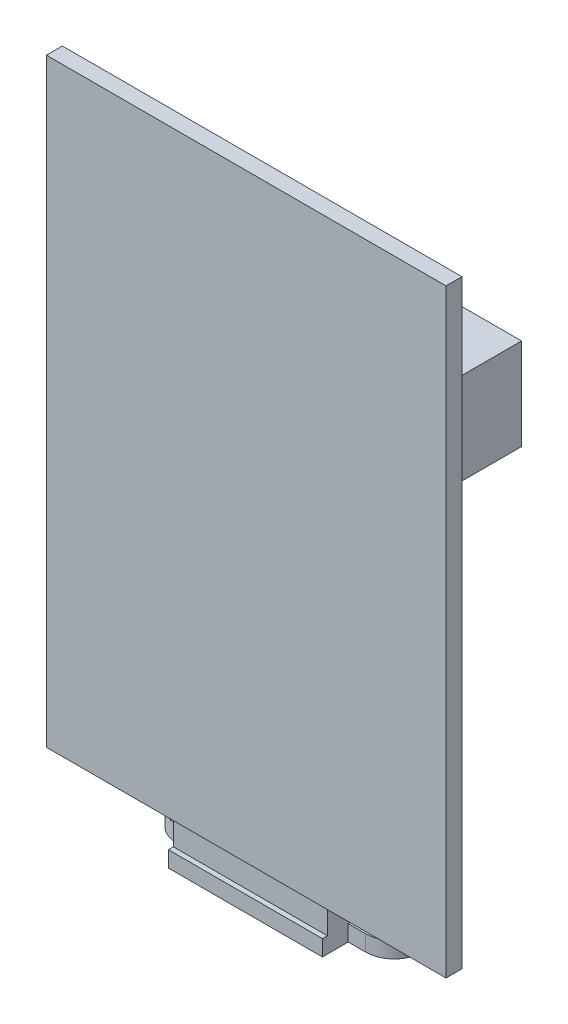
from build123d import *

# Parameters (mm, degrees)
SKETCH1_W           = 15.5
SKETCH1_H           = 11
BOSS_EXTRUDE1_DEPTH = 1.6
BOSS_EXTRUDE2_DEPTH = 1.6
SKETCH3_W           = 15.5
SKETCH3_H           = 2.7
BOSS_EXTRUDE3_DEPTH = 2.7
SKETCH4_W           = 40.2
SKETCH4_H           = 1.6
BOSS_EXTRUDE4_DEPTH = 60.3
SKETCH5_W           = 30.1
SKETCH5_H           = 9.2
BOSS_EXTRUDE5_DEPTH = 12.1
SKETCH6_R           = 2
CUT_EXTRUDE1_DEPTH  = 2
LPATTERN1_COUNT     = 6
LPATTERN1_PITCH     = 5


with BuildPart() as part:
    # Sketch1 → Boss-Extrude1 (new body)
    with BuildSketch(Plane(origin=(0, 0, 0), x_dir=(1, 0, 0), z_dir=(0, 1, 0))):
        with Locations((7.75, -5.5)):
            Rectangle(SKETCH1_W, SKETCH1_H)
    extrude(amount=BOSS_EXTRUDE1_DEPTH)

    # Sketch2 → Boss-Extrude2 (add, through all)
    with BuildSketch(Plane(origin=(0, 1.6, 0), x_dir=(1, 0, 0), z_dir=(0, 1, 0))):
        with BuildLine():
            Line((-1.75, -4), (-1.75, -2.6))
            ThreePointArc((-1.75, -2.6), (-4.65, -5.5), (-1.75, -8.4))
            Line((-1.75, -8.4), (-1.75, -7))
            ThreePointArc((-1.75, -7), (-3.25, -5.5), (-1.75, -4))
        make_face()
        with BuildLine():
            ThreePointArc((0, -3.187533784), (-0.827002716, -2.750804479), (-1.75, -2.6))
            Line((-1.75, -2.6), (-1.75, -4))
            ThreePointArc((-1.75, -4), (-0.689339828, -4.439339828), (-0.25, -5.5))
            ThreePointArc((-0.25, -5.5), (-0.689339828, -6.560660172), (-1.75, -7))
            Line((-1.75, -7), (-1.75, -8.4))
            ThreePointArc((-1.75, -8.4), (-0.827002716, -8.249195521), (0, -7.812466216))
            Line((0, -7.812466216), (0, -3.187533784))
        make_face()
        with BuildLine():
            Line((0, -2.6), (-1.75, -2.6))
            ThreePointArc((-1.75, -2.6), (-0.827002716, -2.750804479), (0, -3.187533784))
            Line((0, -3.187533784), (0, -2.6))
        make_face()
        with BuildLine():
            ThreePointArc((0, -7.812466216), (-0.827002716, -8.249195521), (-1.75, -8.4))
            Line((-1.75, -8.4), (0, -8.4))
            Line((0, -8.4), (0, -7.812466216))
        make_face()
        with BuildLine():
            ThreePointArc((20.15, -5.5), (19.300609665, -3.449390335), (17.25, -2.6))
            Line((17.25, -2.6), (17.25, -4))
            ThreePointArc((17.25, -4), (18.310660172, -4.439339828), (18.75, -5.5))
            ThreePointArc((18.75, -5.5), (18.310660172, -6.560660172), (17.25, -7))
            Line((17.25, -7), (17.25, -8.4))
            ThreePointArc((17.25, -8.4), (19.300609665, -7.550609665), (20.15, -5.5))
        make_face()
        with BuildLine():
            Line((17.25, -4), (17.25, -2.6))
            ThreePointArc((17.25, -2.6), (16.327002716, -2.750804479), (15.5, -3.187533784))
            Line((15.5, -3.187533784), (15.5, -7.812466216))
            ThreePointArc((15.5, -7.812466216), (16.327002716, -8.249195521), (17.25, -8.4))
            Line((17.25, -8.4), (17.25, -7))
            ThreePointArc((17.25, -7), (15.75, -5.5), (17.25, -4))
        make_face()
        with BuildLine():
            Line((17.25, -2.6), (15.5, -2.6))
            Line((15.5, -2.6), (15.5, -3.187533784))
            ThreePointArc((15.5, -3.187533784), (16.327002716, -2.750804479), (17.25, -2.6))
        make_face()
        with BuildLine():
            Line((15.5, -7.812466216), (15.5, -8.4))
            Line((15.5, -8.4), (17.25, -8.4))
            ThreePointArc((17.25, -8.4), (16.327002716, -8.249195521), (15.5, -7.812466216))
        make_face()
    extrude(amount=-BOSS_EXTRUDE2_DEPTH)

    # Sketch3 → Boss-Extrude3 (add)
    with BuildSketch(Plane(origin=(0, 1.6, 0), x_dir=(1, 0, 0), z_dir=(0, 1, 0))):
        with Locations((7.75, -9.15)):
            Rectangle(SKETCH3_W, SKETCH3_H)
    extrude(amount=BOSS_EXTRUDE3_DEPTH)

    # Sketch4 → Boss-Extrude4 (add)
    with BuildSketch(Plane(origin=(0, 4.3, 0), x_dir=(1, 0, 0), z_dir=(0, 1, 0))):
        with Locations((7.75, -10.112281479)):
            Rectangle(SKETCH4_W, SKETCH4_H)
    extrude(amount=BOSS_EXTRUDE4_DEPTH)

    # Sketch5 → Boss-Extrude5 (add)
    with BuildSketch(Plane(origin=(0, 0, 9.312281479), x_dir=(-1, 0, 0), z_dir=(0, 0, -1))):
        with Locations((-6.7, 45.3)):
            Rectangle(SKETCH5_W, SKETCH5_H)
    extrude(amount=BOSS_EXTRUDE5_DEPTH)

    # Sketch6 → Cut-Extrude1 (cut)
    with BuildSketch(Plane(origin=(0, 0, -2.787718521), x_dir=(-1, 0, 0), z_dir=(0, 0, -1))):
        with Locations((-19.35, 45.7)):
            Circle(SKETCH6_R)
    cut_extrude1 = extrude(amount=-CUT_EXTRUDE1_DEPTH, mode=Mode.SUBTRACT)

    # LPattern1: Cut-Extrude1 ×6
    with Locations(*[(-i * LPATTERN1_PITCH, 0, 0) for i in range(1, LPATTERN1_COUNT)]):
        add(cut_extrude1, mode=Mode.SUBTRACT)


solid = part.part
